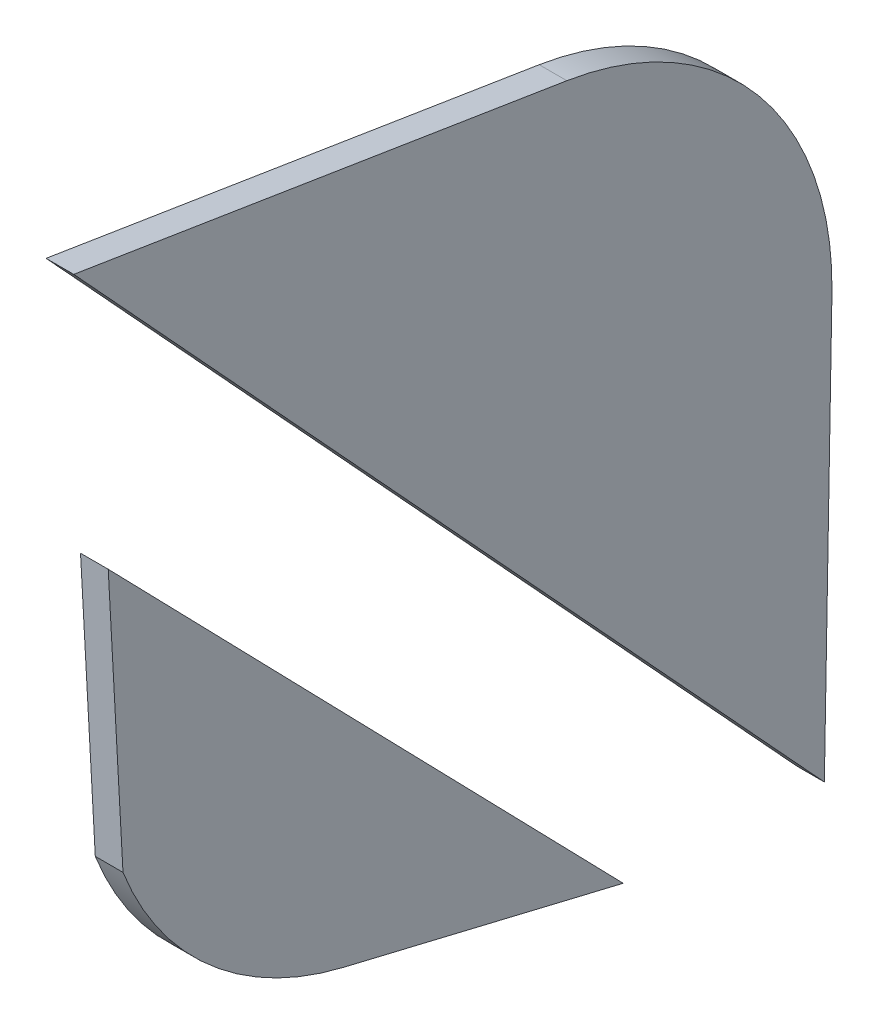
from build123d import *

# Parameters (mm, degrees)
SALIENTE_EXTRUIR1_DEPTH   = 3
SALIENTE_EXTRUIR1_2_DEPTH = 3


with BuildPart() as part:
    # Croquis1 → Saliente-Extruir1 (new body)
    with BuildSketch(Plane(origin=(0, 0, 0), x_dir=(0, 0, -1), z_dir=(1, 0, 0))):
        with BuildLine():
            Line((-38.795102136, 76.851925702), (14.612324216, 68.312789252))
            ThreePointArc((14.612324216, 68.312789252), (35.373203511, 56.532469536), (43.322579124, 34.024749326))
            Line((43.322579124, 34.024749326), (42.501318157, -11.414104273))
            Line((42.501318157, -11.414104273), (-38.795102136, 76.851925702))
        make_face()
    extrude(amount=SALIENTE_EXTRUIR1_DEPTH)


with BuildPart() as body_2:
    # Croquis1 → Saliente-Extruir1 2 (new body)
    with BuildSketch(Plane(origin=(0, 0, 0), x_dir=(0, 0, -1), z_dir=(1, 0, 0))):
        with BuildLine():
            Line((-33.462635017, 18.094168215), (-35.062224892, 47.327776582))
            Line((-35.062224892, 47.327776582), (20.715509479, -10.0206702))
            Line((20.715509479, -10.0206702), (-9.614235223, -2.749860625))
            ThreePointArc((-9.614235223, -2.749860625), (-24.105399402, 4.73519804), (-33.462635017, 18.094168215))
        make_face()
    extrude(amount=SALIENTE_EXTRUIR1_2_DEPTH)


solid = Compound([part.part, body_2.part])
